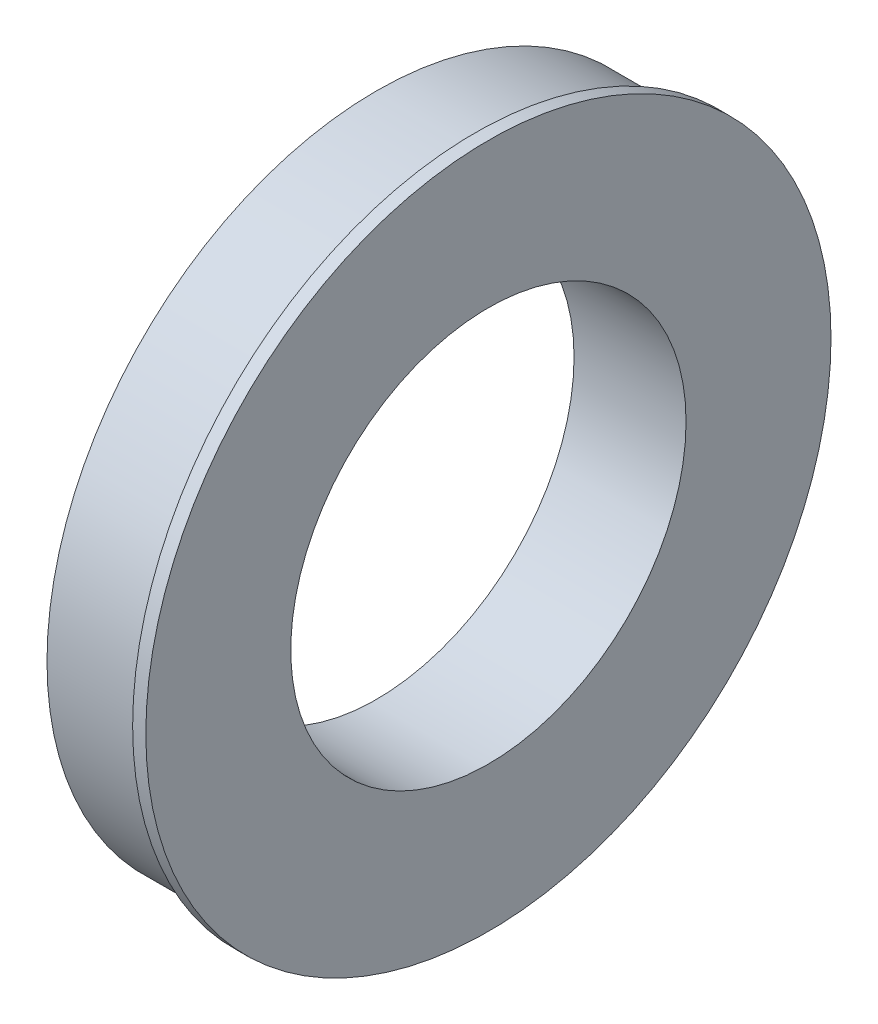
from build123d import *

# Parameters (mm, degrees)
SKETCH1_R           = 63.5
SKETCH1_R_2         = 38.1
BOSS_EXTRUDE1_DEPTH = 19.05
SKETCH3_R           = 66.04
SKETCH3_R_2         = 38.1
BOSS_EXTRUDE2_DEPTH = 2.54


with BuildPart() as part:
    # Sketch1 → Boss-Extrude1 (new body)
    with BuildSketch(Plane(origin=(0, 0, 0), x_dir=(0, 0, -1), z_dir=(1, 0, 0))):
        Circle(SKETCH1_R)
        Circle(SKETCH1_R_2, mode=Mode.SUBTRACT)
    extrude(amount=BOSS_EXTRUDE1_DEPTH)

    # Sketch3 → Boss-Extrude2 (add)
    with BuildSketch(Plane(origin=(19.05, 0, 0), x_dir=(0, 0, -1), z_dir=(1, 0, 0))):
        Circle(SKETCH3_R)
        Circle(SKETCH3_R_2, mode=Mode.SUBTRACT)
    extrude(amount=BOSS_EXTRUDE2_DEPTH)


solid = part.part
